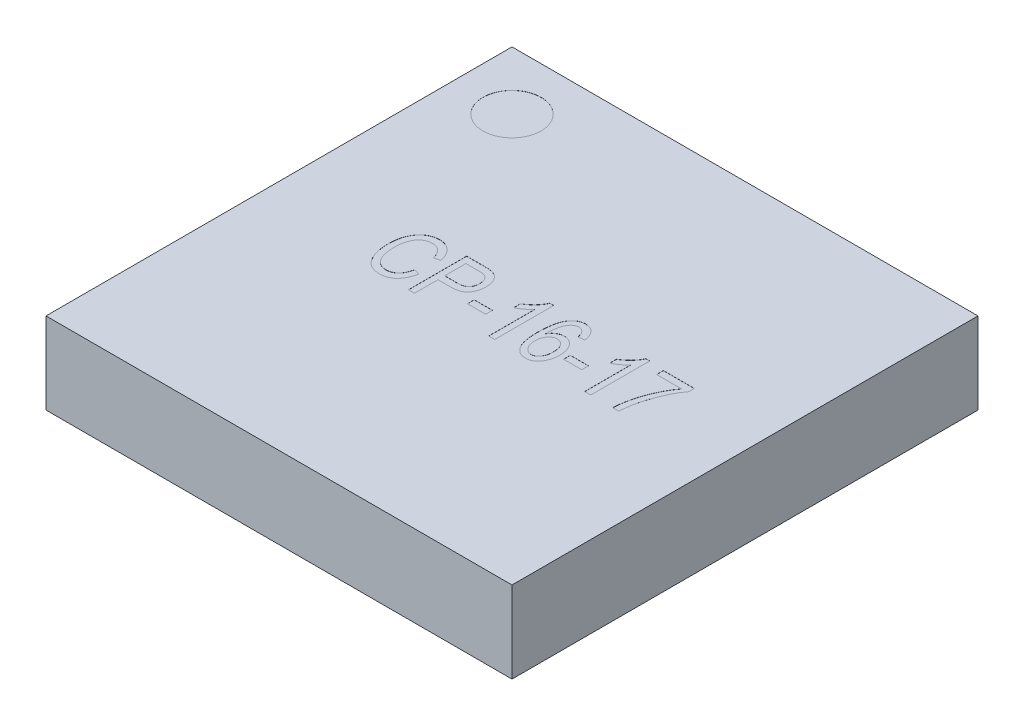
from build123d import *

# Parameters (mm, degrees)
SKETCH1_W           = 4
SKETCH1_H           = 4
BOSS_EXTRUDE1_DEPTH = 0.7
SKETCH2_R           = 0.25
CUT_EXTRUDE1_DEPTH  = 0.001
SKETCH3_W           = 0.155844156
SKETCH3_H           = 0.058441559
CUT_EXTRUDE2_DEPTH  = 0.001


with BuildPart() as part:
    # Sketch1 → Boss-Extrude1 (new body)
    with BuildSketch(Plane(origin=(0, 0, 0), x_dir=(1, 0, 0), z_dir=(0, 1, 0))):
        Rectangle(SKETCH1_W, SKETCH1_H)
    extrude(amount=BOSS_EXTRUDE1_DEPTH)

    # Sketch2 → Cut-Extrude1 (cut)
    with BuildSketch(Plane(origin=(0, 0.7, 0), x_dir=(1, 0, 0), z_dir=(0, 1, 0))):
        with Locations((-1.5, 1.5)):
            Circle(SKETCH2_R)
    extrude(amount=-CUT_EXTRUDE1_DEPTH, mode=Mode.SUBTRACT)

    # Sketch3 → Cut-Extrude2 (cut)
    with BuildSketch(Plane(origin=(0, 0.7, 0), x_dir=(1, 0, 0), z_dir=(0, 1, 0))):
        with BuildLine():
            Line((-0.762337662, -0.074675325), (-0.71038961, -0.087662338))
            add(Edge.make_bspline(
                [(-0.71038961, -0.087662338), (-0.711937931, -0.094546408), (-0.71495651, -0.107967474), (-0.720618368, -0.12727135), (-0.727234375, -0.145186847), (-0.734623355, -0.161781835), (-0.74284456, -0.177058859), (-0.751857521, -0.191007411), (-0.761738106, -0.203616091), (-0.772535533, -0.214729632), (-0.783889364, -0.224701422), (-0.796064053, -0.233071772), (-0.808693317, -0.240407617), (-0.822018459, -0.246250301), (-0.835904982, -0.25087798), (-0.850427644, -0.25407037), (-0.865527439, -0.256209663), (-0.875831216, -0.256398112), (-0.881047078, -0.256493506)],
                knots=[0, 0, 0, 0, 2.1165e-05, 4.1262e-05, 6.0298e-05, 7.8419e-05, 9.5715e-05, 0.000112291, 0.000128185, 0.000143684, 0.000158717, 0.000173438, 0.000187935, 0.000202471, 0.000217005, 0.000231774, 0.000247027, 0.000262664, 0.000262664, 0.000262664, 0.000262664], degree=3))
            add(Edge.make_bspline(
                [(-0.881047078, -0.256493506), (-0.885650513, -0.256429986), (-0.894674325, -0.25630547), (-0.907954108, -0.254897897), (-0.920755284, -0.252841875), (-0.933048215, -0.24974649), (-0.944859981, -0.245957112), (-0.95607654, -0.241090449), (-0.966880151, -0.235551854), (-0.97714716, -0.229006366), (-0.986999545, -0.221591174), (-0.996172899, -0.212969476), (-1.005110946, -0.203544978), (-1.013355655, -0.192867348), (-1.021466681, -0.181362287), (-1.028758606, -0.168599622), (-1.035832642, -0.154952744), (-1.042347248, -0.14031192), (-1.048415169, -0.124824376), (-1.053370407, -0.108467119), (-1.05778992, -0.091524829), (-1.061297468, -0.073866194), (-1.064191493, -0.055564579), (-1.066024161, -0.036520655), (-1.067319454, -0.016826615), (-1.067460669, -0.003451922), (-1.067532468, 0.003348214)],
                knots=[0, 0, 0, 0, 1.3805e-05, 2.706e-05, 4.0021e-05, 5.2669e-05, 6.5054e-05, 7.7191e-05, 8.9307e-05, 0.000101439, 0.000113676, 0.000126241, 0.000139162, 0.000152599, 0.000166672, 0.000181359, 0.000196651, 0.000212773, 0.000229411, 0.000246516, 0.000264013, 0.000281921, 0.000300504, 0.000319575, 0.000339296, 0.000359694, 0.000359694, 0.000359694, 0.000359694], degree=3))
            add(Edge.make_bspline(
                [(-1.067532468, 0.003348214), (-1.067461255, 0.010046956), (-1.067321586, 0.023185277), (-1.066028414, 0.042473955), (-1.06420041, 0.061012927), (-1.061296187, 0.078738564), (-1.057812634, 0.095727996), (-1.053409618, 0.111868156), (-1.048380229, 0.12729183), (-1.042399682, 0.141851517), (-1.035660377, 0.15555882), (-1.028458865, 0.168470775), (-1.020778453, 0.180588553), (-1.012443346, 0.19178802), (-1.003498041, 0.202041368), (-0.994015143, 0.211451277), (-0.983945408, 0.21995922), (-0.973405352, 0.227719151), (-0.962360336, 0.234444624), (-0.951038152, 0.24041722), (-0.939353624, 0.245372865), (-0.927349397, 0.249445127), (-0.915037072, 0.252610614), (-0.902412011, 0.25478704), (-0.889506008, 0.256322126), (-0.880781105, 0.256436042), (-0.87637987, 0.256493506)],
                knots=[0, 0, 0, 0, 2.0093e-05, 3.9409e-05, 5.7976e-05, 7.5957e-05, 9.3269e-05, 0.000109981, 0.00012612, 0.000141909, 0.000157156, 0.000171918, 0.000186244, 0.000200165, 0.000213756, 0.000227029, 0.000240202, 0.000253271, 0.000266253, 0.00027896, 0.000291643, 0.000304284, 0.000316958, 0.000329735, 0.000342699, 0.000355895, 0.000355895, 0.000355895, 0.000355895], degree=3))
            add(Edge.make_bspline(
                [(-0.87637987, 0.256493506), (-0.871573088, 0.25636906), (-0.862130935, 0.256124604), (-0.848184441, 0.25441274), (-0.834843054, 0.251299258), (-0.821882355, 0.24728805), (-0.809545565, 0.241865591), (-0.797673287, 0.235341972), (-0.786369068, 0.227579691), (-0.775625529, 0.21862656), (-0.765454334, 0.208593404), (-0.756085875, 0.197375118), (-0.747605677, 0.185021439), (-0.739684166, 0.171705337), (-0.732861452, 0.157102252), (-0.726709858, 0.141468992), (-0.721108979, 0.124778862), (-0.718315391, 0.11312024), (-0.716883117, 0.107142857)],
                knots=[0, 0, 0, 0, 1.442e-05, 2.8326e-05, 4.2061e-05, 5.5474e-05, 6.8969e-05, 8.2411e-05, 9.606e-05, 0.000110039, 0.000124316, 0.000138865, 0.000153811, 0.000169228, 0.000185294, 0.0002021, 0.000219618, 0.00023805, 0.00023805, 0.00023805, 0.00023805], degree=3))
            Line((-0.716883117, 0.107142857), (-0.768831169, 0.094155844))
            add(Edge.make_bspline(
                [(-0.768831169, 0.094155844), (-0.770005301, 0.098362735), (-0.77229521, 0.106567436), (-0.77637017, 0.118351887), (-0.780827054, 0.129331729), (-0.785670829, 0.139536605), (-0.791064766, 0.148877962), (-0.796851214, 0.157431925), (-0.803040076, 0.165222307), (-0.809761346, 0.17208484), (-0.816791331, 0.178276762), (-0.82434545, 0.183581108), (-0.832360984, 0.188012397), (-0.8407655, 0.191737436), (-0.849585557, 0.194539329), (-0.858850158, 0.19660313), (-0.868534678, 0.197820465), (-0.875158947, 0.197974176), (-0.878510552, 0.198051948)],
                knots=[0, 0, 0, 0, 1.3101e-05, 2.555e-05, 3.7383e-05, 4.8637e-05, 5.9409e-05, 6.9709e-05, 7.9597e-05, 8.9212e-05, 9.8489e-05, 0.000107665, 0.00011684, 0.000125927, 0.0001352, 0.000144554, 0.00015437, 0.000164423, 0.000164423, 0.000164423, 0.000164423], degree=3))
            add(Edge.make_bspline(
                [(-0.878510552, 0.198051948), (-0.885125959, 0.197806854), (-0.898034921, 0.19732859), (-0.916705193, 0.193350322), (-0.934076827, 0.186986931), (-0.947298458, 0.179351247), (-0.957101512, 0.172027485), (-0.964050088, 0.16576623), (-0.970592781, 0.158776333), (-0.976809238, 0.151124356), (-0.982697799, 0.142747711), (-0.988008036, 0.133544422), (-0.993158023, 0.123775583), (-0.99779871, 0.113232669), (-1.00193294, 0.101973654), (-1.00561009, 0.090022902), (-1.0087463, 0.077359263), (-1.011276116, 0.063944193), (-1.013157116, 0.049815621), (-1.014607356, 0.034961924), (-1.015386076, 0.019387425), (-1.015517491, 0.008760232), (-1.015584416, 0.003348214)],
                knots=[0, 0, 0, 0, 1.9829e-05, 3.8693e-05, 5.6993e-05, 7.5127e-05, 8.4259e-05, 9.367e-05, 0.000103145, 0.000112954, 0.000123227, 0.000133825, 0.000144807, 0.000156345, 0.000168351, 0.000180771, 0.000193838, 0.000207469, 0.000221703, 0.000236584, 0.00025223, 0.000268467, 0.000268467, 0.000268467, 0.000268467], degree=3))
            add(Edge.make_bspline(
                [(-1.015584416, 0.003348214), (-1.01545609, -0.004771214), (-1.015207193, -0.020519445), (-1.013620129, -0.043391013), (-1.01084347, -0.064721071), (-1.006767332, -0.084438514), (-1.001732437, -0.10260679), (-0.995606707, -0.11923285), (-0.988157942, -0.13424689), (-0.979648084, -0.147680143), (-0.970153088, -0.159522914), (-0.95990856, -0.169841146), (-0.948849847, -0.178529424), (-0.937111262, -0.18575348), (-0.924518021, -0.191217656), (-0.911246946, -0.195214605), (-0.897196246, -0.197585635), (-0.887583468, -0.197894228), (-0.882670455, -0.198051948)],
                knots=[0, 0, 0, 0, 2.4358e-05, 4.7245e-05, 6.874e-05, 8.8837e-05, 0.000107597, 0.000125255, 0.000141907, 0.000157782, 0.000172867, 0.000187359, 0.000201304, 0.000214963, 0.000228593, 0.000242364, 0.000256458, 0.000271193, 0.000271193, 0.000271193, 0.000271193], degree=3))
            add(Edge.make_bspline(
                [(-0.882670455, -0.198051948), (-0.879012894, -0.197951354), (-0.871805273, -0.197753122), (-0.861179264, -0.19627237), (-0.85090108, -0.193982698), (-0.840996766, -0.190622274), (-0.83157299, -0.186193004), (-0.822439592, -0.181036183), (-0.813785267, -0.174752249), (-0.805489006, -0.167603118), (-0.797721454, -0.159426384), (-0.790620527, -0.150230618), (-0.784079103, -0.14009076), (-0.778467406, -0.128839227), (-0.773364519, -0.116711798), (-0.768909982, -0.10359669), (-0.765149442, -0.089493976), (-0.763289994, -0.079694306), (-0.762337662, -0.074675325)],
                knots=[0, 0, 0, 0, 1.097e-05, 2.1617e-05, 3.2127e-05, 4.2522e-05, 5.2918e-05, 6.3325e-05, 7.3941e-05, 8.4946e-05, 9.6141e-05, 0.00010771, 0.000119756, 0.00013228, 0.000145376, 0.000159205, 0.000173799, 0.000189121, 0.000189121, 0.000189121, 0.000189121], degree=3))
        make_face()
        with BuildLine():
            Line((-0.638961039, -0.25), (-0.638961039, 0.25))
            Line((-0.638961039, 0.25), (-0.484943182, 0.25))
            add(Edge.make_bspline(
                [(-0.484943182, 0.25), (-0.480545606, 0.250004127), (-0.472085326, 0.250012065), (-0.459844064, 0.249413169), (-0.448463231, 0.248807999), (-0.437982749, 0.247640288), (-0.428394687, 0.24636519), (-0.419708838, 0.244771801), (-0.411923469, 0.242758027), (-0.407080716, 0.241131112), (-0.404788961, 0.240361201)],
                knots=[0, 0, 0, 0, 1.319e-05, 2.5376e-05, 3.6762e-05, 4.7373e-05, 5.7001e-05, 6.5777e-05, 7.3848e-05, 8.11e-05, 8.11e-05, 8.11e-05, 8.11e-05], degree=3))
            add(Edge.make_bspline(
                [(-0.404788961, 0.240361201), (-0.401887015, 0.23923799), (-0.39609, 0.236994229), (-0.387924573, 0.232564588), (-0.380135314, 0.227574152), (-0.372810501, 0.221892907), (-0.365993094, 0.215433289), (-0.359576379, 0.208337229), (-0.35368784, 0.20045885), (-0.348262365, 0.191965953), (-0.343210408, 0.18294422), (-0.339039192, 0.173283331), (-0.335292201, 0.163186971), (-0.332441311, 0.152536886), (-0.330032039, 0.141408411), (-0.328497522, 0.129767818), (-0.327403811, 0.117614214), (-0.327317086, 0.109343835), (-0.327272727, 0.105113636)],
                knots=[0, 0, 0, 0, 9.327e-06, 1.8631e-05, 2.7806e-05, 3.7061e-05, 4.6392e-05, 5.5947e-05, 6.5728e-05, 7.586e-05, 8.6168e-05, 9.6707e-05, 0.000107395, 0.000118447, 0.00012975, 0.00014153, 0.000153647, 0.000166333, 0.000166333, 0.000166333, 0.000166333], degree=3))
            add(Edge.make_bspline(
                [(-0.327272727, 0.105113636), (-0.327358616, 0.099563106), (-0.327526593, 0.08870757), (-0.32917587, 0.072830024), (-0.331916917, 0.057775854), (-0.335656782, 0.043472741), (-0.340513882, 0.029942284), (-0.346528332, 0.017220039), (-0.353583989, 0.005260443), (-0.361639037, -0.005958818), (-0.371131137, -0.016171052), (-0.382333671, -0.024907544), (-0.395008345, -0.032379539), (-0.409313382, -0.038318606), (-0.425102864, -0.043115766), (-0.442519935, -0.046386056), (-0.4614973, -0.04828016), (-0.474657263, -0.048557321), (-0.481493506, -0.048701299)],
                knots=[0, 0, 0, 0, 1.6647e-05, 3.2558e-05, 4.7822e-05, 6.2515e-05, 7.6861e-05, 9.0885e-05, 0.000104667, 0.000118467, 0.000132249, 0.000146336, 0.000160935, 0.000176256, 0.00019269, 0.000210359, 0.000229329, 0.000249837, 0.000249837, 0.000249837, 0.000249837], degree=3))
            Line((-0.481493506, -0.048701299), (-0.587012987, -0.048701299))
            Line((-0.587012987, -0.048701299), (-0.587012987, -0.25))
            Line((-0.587012987, -0.25), (-0.638961039, -0.25))
        make_face()
        with BuildLine():
            Line((-0.587012987, 0.00974026), (-0.478246753, 0.00974026))
            add(Edge.make_bspline(
                [(-0.478246753, 0.00974026), (-0.474119131, 0.009832994), (-0.466121819, 0.010012668), (-0.454514054, 0.010971012), (-0.44376189, 0.012798789), (-0.43386881, 0.015301816), (-0.424862353, 0.018565771), (-0.416697591, 0.022490552), (-0.40942114, 0.027214472), (-0.402918374, 0.032613892), (-0.39737604, 0.038887419), (-0.392390465, 0.045721155), (-0.388347284, 0.053437778), (-0.385043156, 0.061854181), (-0.38235929, 0.070942926), (-0.380588456, 0.080774564), (-0.379456556, 0.091322325), (-0.379300933, 0.098617035), (-0.379220779, 0.102374188)],
                knots=[0, 0, 0, 0, 1.2385e-05, 2.3996e-05, 3.4905e-05, 4.5068e-05, 5.4569e-05, 6.3599e-05, 7.2182e-05, 8.0535e-05, 8.8869e-05, 9.7231e-05, 0.000105855, 0.000114918, 0.000124325, 0.000134235, 0.000144846, 0.000156115, 0.000156115, 0.000156115, 0.000156115], degree=3))
            add(Edge.make_bspline(
                [(-0.379220779, 0.102374188), (-0.379336176, 0.107254453), (-0.379559476, 0.116698047), (-0.381869223, 0.130281714), (-0.385442163, 0.142812329), (-0.390671392, 0.15403784), (-0.396786914, 0.163881515), (-0.40348337, 0.172302067), (-0.410962472, 0.178917646), (-0.417923043, 0.183040966), (-0.424035948, 0.185641458), (-0.429483379, 0.187246243), (-0.435773599, 0.188506759), (-0.442883904, 0.189610581), (-0.450800445, 0.19054132), (-0.459538326, 0.191089687), (-0.46911063, 0.191539682), (-0.475777215, 0.191552003), (-0.479261364, 0.191558442)],
                knots=[0, 0, 0, 0, 1.4628e-05, 2.8305e-05, 4.1211e-05, 5.3605e-05, 6.5317e-05, 7.5918e-05, 8.5769e-05, 9.5095e-05, 0.000100051, 0.000105668, 0.000112096, 0.000119285, 0.000127252, 0.000135999, 0.000145544, 0.000155995, 0.000155995, 0.000155995, 0.000155995], degree=3))
            Line((-0.479261364, 0.191558442), (-0.587012987, 0.191558442))
            Line((-0.587012987, 0.191558442), (-0.587012987, 0.00974026))
        make_face(mode=Mode.SUBTRACT)
        with Locations((-0.203896104, -0.071428572)):
            Rectangle(SKETCH3_W, SKETCH3_H)
        with BuildLine():
            Line((0.101298701, -0.25), (0.049350649, -0.25))
            Line((0.049350649, -0.25), (0.049350649, 0.146103896))
            add(Edge.make_bspline(
                [(0.049350649, 0.146103896), (0.04616033, 0.142431565), (0.039548396, 0.134820662), (0.028070418, 0.123996897), (0.015279479, 0.112835387), (0.001118212, 0.10200478), (-0.013310992, 0.09163081), (-0.027562513, 0.082506724), (-0.04110221, 0.074568081), (-0.050185435, 0.070253062), (-0.054545455, 0.068181818)],
                knots=[0, 0, 0, 0, 1.4585e-05, 3.0228e-05, 4.7275e-05, 6.55e-05, 8.3687e-05, 0.000100573, 0.000116254, 0.000130729, 0.000130729, 0.000130729, 0.000130729], degree=3))
            Line((-0.054545455, 0.068181818), (-0.054545455, 0.126623377))
            add(Edge.make_bspline(
                [(-0.054545455, 0.126623377), (-0.047538551, 0.130840398), (-0.033584743, 0.139238331), (-0.014033631, 0.153786262), (0.004436051, 0.169488363), (0.02127225, 0.186509155), (0.036347218, 0.204055044), (0.049286408, 0.221565862), (0.059895725, 0.23885556), (0.065099935, 0.250748878), (0.067613636, 0.256493506)],
                knots=[0, 0, 0, 0, 2.4521e-05, 4.8832e-05, 7.301e-05, 9.7188e-05, 0.000120574, 0.000142348, 0.000162463, 0.000181256, 0.000181256, 0.000181256, 0.000181256], degree=3))
            Line((0.067613636, 0.256493506), (0.101298701, 0.256493506))
            Line((0.101298701, 0.256493506), (0.101298701, -0.25))
        make_face()
        with BuildLine():
            Line((0.490909091, 0.133116883), (0.438961039, 0.126623377))
            add(Edge.make_bspline(
                [(0.438961039, 0.126623377), (0.437760263, 0.132539718), (0.43551176, 0.143618317), (0.430634782, 0.158626308), (0.425200928, 0.171174435), (0.420175915, 0.177832634), (0.417857143, 0.180905032)],
                knots=[0, 0, 0, 0, 1.8092e-05, 3.3878e-05, 4.7314e-05, 5.8826e-05, 5.8826e-05, 5.8826e-05, 5.8826e-05], degree=3))
            add(Edge.make_bspline(
                [(0.417857143, 0.180905032), (0.416170888, 0.182803084), (0.412892098, 0.186493693), (0.407442735, 0.191274378), (0.401832171, 0.195394547), (0.395931925, 0.19878704), (0.389672446, 0.20132346), (0.383170258, 0.203138926), (0.37643396, 0.204296314), (0.371866058, 0.204461914), (0.369561688, 0.204545455)],
                knots=[0, 0, 0, 0, 7.61e-06, 1.4798e-05, 2.1698e-05, 2.8468e-05, 3.5157e-05, 4.1902e-05, 4.8691e-05, 5.5602e-05, 5.5602e-05, 5.5602e-05, 5.5602e-05], degree=3))
            add(Edge.make_bspline(
                [(0.369561688, 0.204545455), (0.365991842, 0.204413003), (0.358919258, 0.204150589), (0.348655455, 0.201321509), (0.338884328, 0.197073504), (0.329742546, 0.190929688), (0.321212672, 0.183107343), (0.313113179, 0.173680255), (0.305748688, 0.162432025), (0.301473475, 0.154161107), (0.299249188, 0.149857955)],
                knots=[0, 0, 0, 0, 1.0684e-05, 2.1168e-05, 3.1706e-05, 4.2541e-05, 5.4034e-05, 6.6337e-05, 7.9732e-05, 9.4259e-05, 9.4259e-05, 9.4259e-05, 9.4259e-05], degree=3))
            add(Edge.make_bspline(
                [(0.299249188, 0.149857955), (0.297382379, 0.145727563), (0.293501242, 0.13714039), (0.288950023, 0.12314667), (0.284950579, 0.107809406), (0.281951731, 0.09099468), (0.279225292, 0.07287671), (0.277486948, 0.053294236), (0.276350819, 0.032345839), (0.276195861, 0.017892618), (0.276116071, 0.010450487)],
                knots=[0, 0, 0, 0, 1.3589e-05, 2.8252e-05, 4.4075e-05, 6.1109e-05, 7.9461e-05, 9.9027e-05, 0.000120059, 0.000142384, 0.000142384, 0.000142384, 0.000142384], degree=3))
            add(Edge.make_bspline(
                [(0.276116071, 0.010450487), (0.279057431, 0.01551462), (0.284780742, 0.025368434), (0.295445743, 0.038279404), (0.306880861, 0.04953138), (0.319578937, 0.058572566), (0.332982553, 0.065666168), (0.346830648, 0.070923047), (0.361132725, 0.07409464), (0.370797516, 0.074481245), (0.375649351, 0.074675325)],
                knots=[0, 0, 0, 0, 1.7541e-05, 3.4132e-05, 5.0062e-05, 6.5548e-05, 8.0708e-05, 9.5445e-05, 0.000109872, 0.000124417, 0.000124417, 0.000124417, 0.000124417], degree=3))
            add(Edge.make_bspline(
                [(0.375649351, 0.074675325), (0.379682398, 0.074535033), (0.387631275, 0.074258527), (0.399361092, 0.072165991), (0.410652848, 0.068686178), (0.42161135, 0.063900447), (0.432127674, 0.057606807), (0.442276469, 0.050003777), (0.451930386, 0.040934174), (0.461258462, 0.030793441), (0.469726363, 0.019370437), (0.477153395, 0.00692614), (0.483491015, -0.006409096), (0.488521112, -0.020753335), (0.492599778, -0.03593606), (0.495430972, -0.052095564), (0.49701728, -0.069164335), (0.497272109, -0.080861177), (0.497402597, -0.086850649)],
                knots=[0, 0, 0, 0, 1.2095e-05, 2.3838e-05, 3.5617e-05, 4.7474e-05, 5.962e-05, 7.2302e-05, 8.5441e-05, 9.9303e-05, 0.000113589, 0.000128014, 0.000142718, 0.000157802, 0.000173553, 0.000189833, 0.000206956, 0.000224925, 0.000224925, 0.000224925, 0.000224925], degree=3))
            add(Edge.make_bspline(
                [(0.497402597, -0.086850649), (0.497195454, -0.094978818), (0.496789684, -0.110901027), (0.493388768, -0.134213484), (0.487663062, -0.156327725), (0.481173276, -0.173854145), (0.474939177, -0.186991525), (0.469947521, -0.196164457), (0.464692289, -0.2046855), (0.459128185, -0.212569264), (0.453086039, -0.219631867), (0.446897105, -0.226218409), (0.440313118, -0.232094808), (0.431187766, -0.238915005), (0.419184363, -0.245962615), (0.403850596, -0.251997477), (0.387807324, -0.255812054), (0.376820167, -0.256265254), (0.371286526, -0.256493506)],
                knots=[0, 0, 0, 0, 2.4376e-05, 4.775e-05, 7.0489e-05, 9.2802e-05, 0.000103694, 0.000114092, 0.000124115, 0.000133716, 0.000143005, 0.000151975, 0.000160814, 0.000169438, 0.000186126, 0.000202386, 0.000218729, 0.000235312, 0.000235312, 0.000235312, 0.000235312], degree=3))
            add(Edge.make_bspline(
                [(0.371286526, -0.256493506), (0.366302106, -0.256319312), (0.356498475, -0.255976697), (0.342153154, -0.253222668), (0.328432152, -0.248912958), (0.315488395, -0.242567847), (0.303038751, -0.23476283), (0.291516305, -0.224886276), (0.280571683, -0.213400512), (0.270244896, -0.200180278), (0.260957562, -0.184773022), (0.252854303, -0.16712178), (0.24608438, -0.147085698), (0.240750135, -0.124712553), (0.236374756, -0.100053191), (0.233298752, -0.073083608), (0.231488023, -0.043754851), (0.231277967, -0.023440215), (0.231168831, -0.012885552)],
                knots=[0, 0, 0, 0, 1.4943e-05, 2.939e-05, 4.3669e-05, 5.7964e-05, 7.2515e-05, 8.7637e-05, 0.000103353, 0.000120056, 0.000137857, 0.000157195, 0.000178211, 0.000201195, 0.000226134, 0.000253305, 0.000282583, 0.000314244, 0.000314244, 0.000314244, 0.000314244], degree=3))
            add(Edge.make_bspline(
                [(0.231168831, -0.012885552), (0.231264893, -0.001180454), (0.23144994, 0.021367603), (0.233436291, 0.053896473), (0.23644185, 0.083817751), (0.240918056, 0.111119862), (0.24647229, 0.135846818), (0.2534611, 0.157945374), (0.261573025, 0.17751216), (0.271223815, 0.194421041), (0.281863415, 0.209015803), (0.293138101, 0.221676354), (0.305078401, 0.232495882), (0.317813706, 0.241318143), (0.331377531, 0.248047424), (0.345569491, 0.253006414), (0.360552187, 0.255877695), (0.370767276, 0.256286132), (0.375953734, 0.256493506)],
                knots=[0, 0, 0, 0, 3.5111e-05, 6.7636e-05, 9.7731e-05, 0.000125287, 0.000150588, 0.000173691, 0.000194741, 0.000214008, 0.000231949, 0.000248834, 0.000264785, 0.000280179, 0.000295153, 0.000310073, 0.000325156, 0.000340713, 0.000340713, 0.000340713, 0.000340713], degree=3))
            add(Edge.make_bspline(
                [(0.375953734, 0.256493506), (0.379711208, 0.256386295), (0.387117924, 0.256174959), (0.39801714, 0.254794932), (0.408392654, 0.252198415), (0.41834085, 0.248760304), (0.427766917, 0.244255887), (0.436815788, 0.238887666), (0.445209916, 0.232286894), (0.453245016, 0.224913694), (0.460679352, 0.216595132), (0.467288244, 0.20727401), (0.473149109, 0.197097067), (0.47839352, 0.186067742), (0.482702939, 0.174090661), (0.486226052, 0.161223821), (0.489122002, 0.147508684), (0.490302959, 0.137998191), (0.490909091, 0.133116883)],
                knots=[0, 0, 0, 0, 1.1274e-05, 2.2222e-05, 3.2878e-05, 4.3307e-05, 5.3745e-05, 6.4168e-05, 7.4802e-05, 8.5716e-05, 9.6855e-05, 0.000108201, 0.00011993, 0.000132048, 0.000144791, 0.000158059, 0.000172048, 0.000186799, 0.000186799, 0.000186799, 0.000186799], degree=3))
        make_face()
        with BuildLine():
            add(Edge.make_bspline(
                [(0.283116883, -0.08492289), (0.283191055, -0.089322323), (0.283335704, -0.097902083), (0.284571581, -0.110450157), (0.286611596, -0.122306332), (0.289287529, -0.133576247), (0.29299048, -0.144099435), (0.297323776, -0.154068938), (0.302632713, -0.1632722), (0.308599355, -0.171804233), (0.315116949, -0.179425669), (0.321993695, -0.18609685), (0.32904168, -0.191823378), (0.336468128, -0.19641864), (0.344076022, -0.200164336), (0.352055293, -0.20265865), (0.360230584, -0.204260465), (0.365766359, -0.204450165), (0.368547078, -0.204545455)],
                knots=[0, 0, 0, 0, 1.3196e-05, 2.5735e-05, 3.7778e-05, 4.927e-05, 6.0437e-05, 7.1202e-05, 8.1836e-05, 9.2251e-05, 0.000102398, 0.000111869, 0.000120964, 0.000129579, 0.00013802, 0.00014633, 0.000154588, 0.000162924, 0.000162924, 0.000162924, 0.000162924], degree=3))
            add(Edge.make_bspline(
                [(0.368547078, -0.204545455), (0.371021714, -0.204438836), (0.375943799, -0.204226769), (0.383202592, -0.202800615), (0.390187435, -0.200268692), (0.397041735, -0.196937708), (0.403624566, -0.192493736), (0.410084186, -0.187226853), (0.416122978, -0.180803232), (0.422152397, -0.173702275), (0.427544773, -0.165564298), (0.432506425, -0.156782723), (0.436367283, -0.147110196), (0.439800172, -0.136875174), (0.442239158, -0.125809043), (0.444247735, -0.114106673), (0.445172345, -0.101610843), (0.445358597, -0.093074492), (0.445454545, -0.088676948)],
                knots=[0, 0, 0, 0, 7.424e-06, 1.4766e-05, 2.2083e-05, 2.9661e-05, 3.7568e-05, 4.5856e-05, 5.461e-05, 6.3977e-05, 7.377e-05, 8.3851e-05, 9.4177e-05, 0.000104957, 0.000116205, 0.000128131, 0.000140551, 0.000153747, 0.000153747, 0.000153747, 0.000153747], degree=3))
            add(Edge.make_bspline(
                [(0.445454545, -0.088676948), (0.44536216, -0.08438028), (0.445182946, -0.076045412), (0.444211484, -0.063865779), (0.442372691, -0.052445501), (0.439908087, -0.04172307), (0.436479556, -0.03185585), (0.432580538, -0.022623781), (0.427771988, -0.014177538), (0.422298635, -0.006491043), (0.416368535, 0.000392768), (0.409985833, 0.006349357), (0.403350327, 0.011433075), (0.396312848, 0.015540001), (0.389029155, 0.018852725), (0.3812908, 0.021028414), (0.373308288, 0.022551904), (0.367844162, 0.022668607), (0.365097403, 0.022727273)],
                knots=[0, 0, 0, 0, 1.2892e-05, 2.5008e-05, 3.6618e-05, 4.7569e-05, 5.7965e-05, 6.7917e-05, 7.7595e-05, 8.7054e-05, 9.6188e-05, 0.000104802, 0.000113203, 0.000121208, 0.000129202, 0.000137132, 0.000145273, 0.000153501, 0.000153501, 0.000153501, 0.000153501], degree=3))
            add(Edge.make_bspline(
                [(0.365097403, 0.022727273), (0.362383984, 0.022671033), (0.357019394, 0.022559844), (0.349175487, 0.021015742), (0.3415409, 0.018839201), (0.334245484, 0.015494161), (0.327099438, 0.01145714), (0.320232157, 0.006442133), (0.313793328, 0.000369424), (0.307484444, -0.006361701), (0.301738052, -0.013919527), (0.296738045, -0.022183633), (0.292586013, -0.031081774), (0.289119279, -0.040585074), (0.28636819, -0.050762073), (0.284483007, -0.061596293), (0.28335793, -0.073061975), (0.283198728, -0.080895648), (0.283116883, -0.08492289)],
                knots=[0, 0, 0, 0, 8.127e-06, 1.6068e-05, 2.3901e-05, 3.1895e-05, 4.0075e-05, 4.8497e-05, 5.7328e-05, 6.659e-05, 7.6148e-05, 8.5753e-05, 9.5511e-05, 0.000105558, 0.000116068, 0.000127094, 0.000138512, 0.000150593, 0.000150593, 0.000150593, 0.000150593], degree=3))
        make_face(mode=Mode.SUBTRACT)
        with Locations((0.620779221, -0.071428572)):
            Rectangle(SKETCH3_W, SKETCH3_H)
        with BuildLine():
            Line((0.925974026, -0.25), (0.874025974, -0.25))
            Line((0.874025974, -0.25), (0.874025974, 0.146103896))
            add(Edge.make_bspline(
                [(0.874025974, 0.146103896), (0.870835655, 0.142431565), (0.864223721, 0.134820662), (0.852745742, 0.123996897), (0.839954804, 0.112835387), (0.825793536, 0.10200478), (0.811364332, 0.09163081), (0.797112812, 0.082506724), (0.783573115, 0.074568081), (0.77448989, 0.070253062), (0.77012987, 0.068181818)],
                knots=[0, 0, 0, 0, 1.4585e-05, 3.0228e-05, 4.7275e-05, 6.55e-05, 8.3687e-05, 0.000100573, 0.000116254, 0.000130729, 0.000130729, 0.000130729, 0.000130729], degree=3))
            Line((0.77012987, 0.068181818), (0.77012987, 0.126623377))
            add(Edge.make_bspline(
                [(0.77012987, 0.126623377), (0.777136773, 0.130840398), (0.791090582, 0.139238331), (0.810641693, 0.153786262), (0.829111376, 0.169488363), (0.845947575, 0.186509155), (0.861022542, 0.204055044), (0.873961733, 0.221565862), (0.88457105, 0.23885556), (0.88977526, 0.250748878), (0.892288961, 0.256493506)],
                knots=[0, 0, 0, 0, 2.4521e-05, 4.8832e-05, 7.301e-05, 9.7188e-05, 0.000120574, 0.000142348, 0.000162463, 0.000181256, 0.000181256, 0.000181256, 0.000181256], degree=3))
            Line((0.892288961, 0.256493506), (0.925974026, 0.256493506))
            Line((0.925974026, 0.256493506), (0.925974026, -0.25))
        make_face()
        with BuildLine():
            Line((1.055844156, 0.185064935), (1.055844156, 0.243506494))
            Line((1.055844156, 0.243506494), (1.322077922, 0.243506494))
            Line((1.322077922, 0.243506494), (1.322077922, 0.195718344))
            add(Edge.make_bspline(
                [(1.322077922, 0.195718344), (1.317138245, 0.189104999), (1.307083762, 0.175643843), (1.29302285, 0.154111277), (1.279348008, 0.131178753), (1.266046419, 0.106826884), (1.253274351, 0.080977411), (1.240902907, 0.053711415), (1.229047574, 0.024926342), (1.217701109, -0.005012039), (1.207068601, -0.035632733), (1.197651152, -0.066470441), (1.189404551, -0.097227447), (1.18243069, -0.12790234), (1.17648722, -0.158479316), (1.171842486, -0.189011719), (1.16834011, -0.219506672), (1.166935073, -0.239847257), (1.166233766, -0.25)],
                knots=[0, 0, 0, 0, 2.4758e-05, 5.0394e-05, 7.7104e-05, 0.000104846, 0.000133614, 0.000163583, 0.000194653, 0.000226989, 0.000259622, 0.000291877, 0.000323699, 0.00035513, 0.000386231, 0.000417126, 0.000447759, 0.000478287, 0.000478287, 0.000478287, 0.000478287], degree=3))
            Line((1.166233766, -0.25), (1.114285714, -0.25))
            add(Edge.make_bspline(
                [(1.114285714, -0.25), (1.114446218, -0.244654166), (1.114773646, -0.233748666), (1.116087236, -0.217075612), (1.11774313, -0.199704687), (1.120224628, -0.181712577), (1.123274827, -0.163072191), (1.126981559, -0.143807072), (1.131071072, -0.123818632), (1.1376195, -0.096427281), (1.146849266, -0.062117461), (1.160113439, -0.021716867), (1.175066676, 0.017760269), (1.192085165, 0.055808131), (1.210233049, 0.092056531), (1.229344542, 0.125750698), (1.248864529, 0.15683249), (1.263167656, 0.17582171), (1.27012987, 0.185064935)],
                knots=[0, 0, 0, 0, 1.6042e-05, 3.2726e-05, 5.0162e-05, 6.8385e-05, 8.7201e-05, 0.000106821, 0.000127237, 0.000148402, 0.000191303, 0.000233784, 0.000275917, 0.000317887, 0.000358769, 0.00039748, 0.00043407, 0.000468772, 0.000468772, 0.000468772, 0.000468772], degree=3))
            Line((1.27012987, 0.185064935), (1.055844156, 0.185064935))
        make_face()
    extrude(amount=-CUT_EXTRUDE2_DEPTH, mode=Mode.SUBTRACT)


solid = part.part
